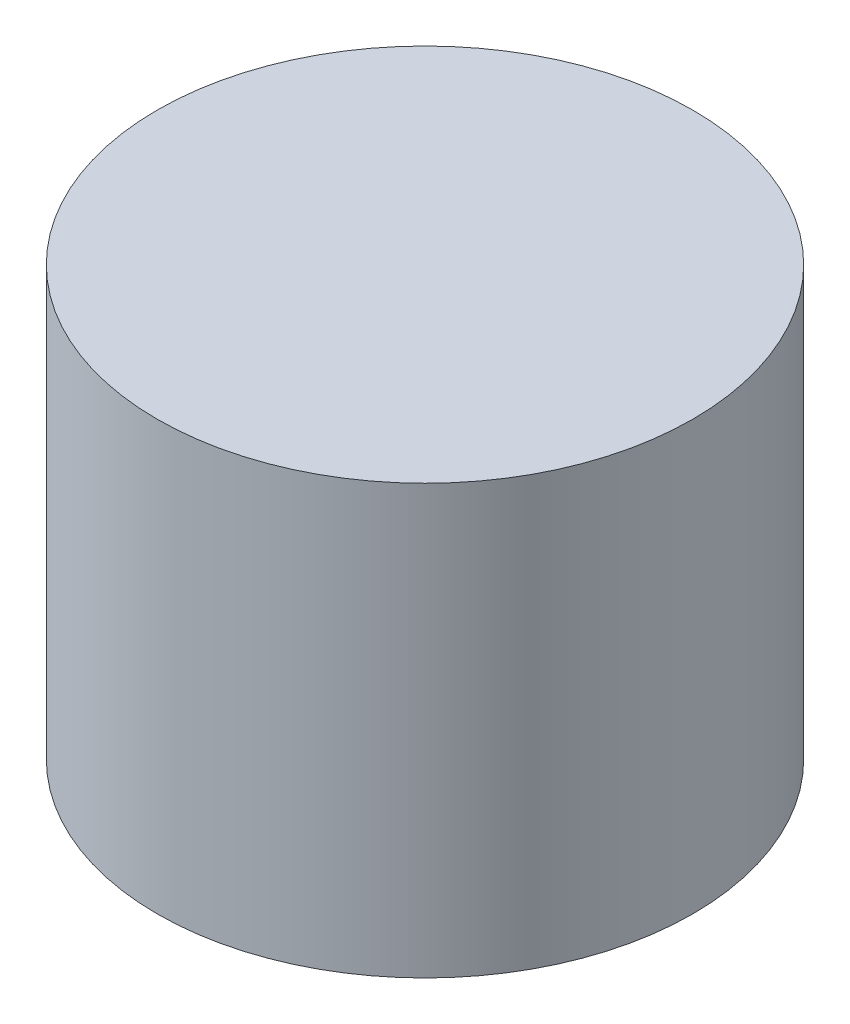
from build123d import *

# Parameters (mm, degrees)
SKETCH1_R           = 12.5
BOSS_EXTRUDE1_DEPTH = 20
SKETCH2_R           = 2
CUT_EXTRUDE1_DEPTH  = 5


with BuildPart() as part:
    # Sketch1 → Boss-Extrude1 (new body)
    with BuildSketch(Plane(origin=(0, 0, 0), x_dir=(1, 0, 0), z_dir=(0, 1, 0))):
        Circle(SKETCH1_R)
    extrude(amount=BOSS_EXTRUDE1_DEPTH)

    # Sketch2 → Cut-Extrude1 (cut)
    with BuildSketch(Plane.XZ):
        Circle(SKETCH2_R)
    extrude(amount=-CUT_EXTRUDE1_DEPTH, mode=Mode.SUBTRACT)


solid = part.part
